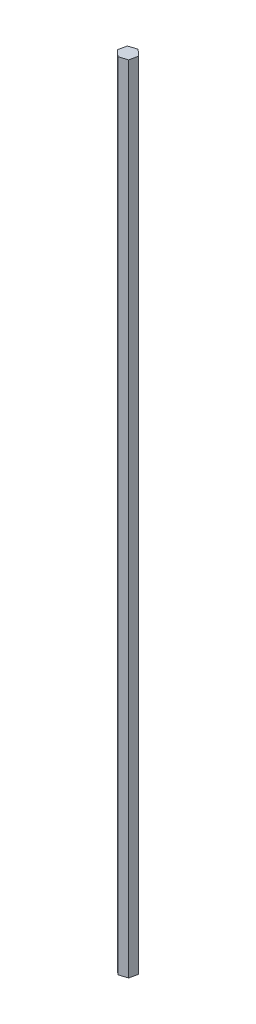
from build123d import *

# Parameters (mm, degrees)
BOSS_EXTRUDE1_DEPTH = 685.8


with BuildPart() as part:
    # Sketch1 → Boss-Extrude1 (new body)
    with BuildSketch(Plane(origin=(0, 0, 0), x_dir=(1, 0, 0), z_dir=(0, 1, 0))):
        Polygon((2.083575367, -0.365699732), (3.622703428, 6.803290305), (-1.816260032, 11.720709324), (-8.794351554, 9.469138307), (-10.333479615, 2.30014827), (-4.894516155, -2.617270749), align=None)
    extrude(amount=BOSS_EXTRUDE1_DEPTH)


solid = part.part
